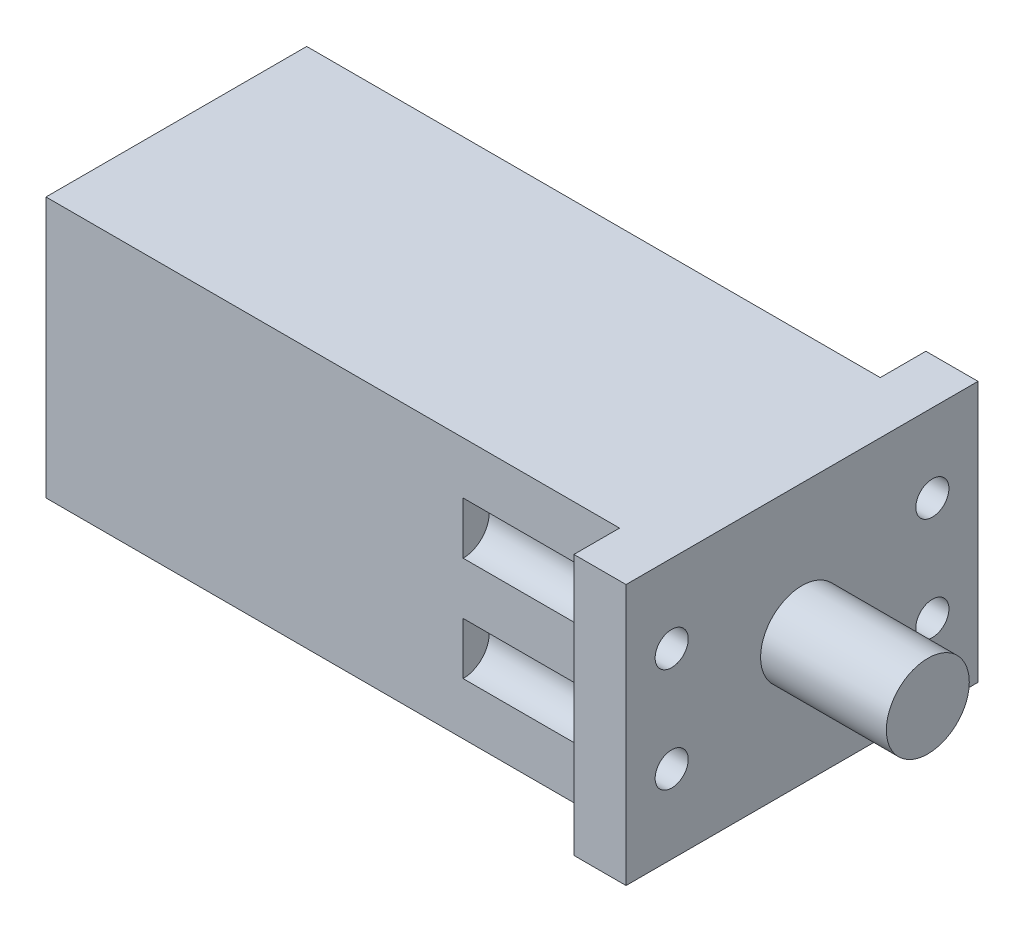
from build123d import *

# Parameters (mm, degrees)
SKETCH1_W           = 100
SKETCH1_H           = 100
BOSS_EXTRUDE1_DEPTH = 240
SKETCH3_W           = 20
SKETCH3_H           = 100
BOSS_EXTRUDE2_DEPTH = 17.5
SKETCH4_W           = 20
SKETCH4_H           = 100
BOSS_EXTRUDE3_DEPTH = 17.5
BOSS_EXTRUDE4_DEPTH = 48.26
CUT_EXTRUDE1_DEPTH  = 20
SKETCH8_R           = 10
CUT_EXTRUDE2_DEPTH  = 60


with BuildPart() as part:
    # Sketch1 → Boss-Extrude1 (new body)
    with BuildSketch(Plane(origin=(0, 0, 0), x_dir=(0, 0, -1), z_dir=(1, 0, 0))):
        with Locations((50, 50)):
            Rectangle(SKETCH1_W, SKETCH1_H)
    extrude(amount=BOSS_EXTRUDE1_DEPTH)

    # Sketch3 → Boss-Extrude2 (add)
    with BuildSketch(Plane.XY):
        with Locations((230, 50)):
            Rectangle(SKETCH3_W, SKETCH3_H)
    extrude(amount=BOSS_EXTRUDE2_DEPTH)

    # Sketch4 → Boss-Extrude3 (add)
    with BuildSketch(Plane(origin=(0, 0, -100), x_dir=(-1, 0, 0), z_dir=(0, 0, -1))):
        with Locations((-230, 50)):
            Rectangle(SKETCH4_W, SKETCH4_H)
    extrude(amount=BOSS_EXTRUDE3_DEPTH)

    # Sketch6 → Boss-Extrude4 (add)
    with BuildSketch(Plane(origin=(240, 0, 0), x_dir=(0, 0, -1), z_dir=(1, 0, 0))):
        with BuildLine():
            ThreePointArc((65.9, 50), (61.242997821, 61.242997821), (50, 65.9))
            Line((50, 65.9), (50, 50))
            Line((50, 50), (34.1, 50))
            ThreePointArc((34.1, 50), (50, 34.1), (65.9, 50))
        make_face()
        with BuildLine():
            Line((50, 50), (50, 65.9))
            ThreePointArc((50, 65.9), (38.757002179, 61.242997821), (34.1, 50))
            Line((34.1, 50), (50, 50))
        make_face()
    extrude(amount=BOSS_EXTRUDE4_DEPTH)

    # Sketch7 → Cut-Extrude1 (cut)
    with BuildSketch(Plane(origin=(240, 0, 0), x_dir=(0, 0, -1), z_dir=(1, 0, 0))):
        with BuildLine():
            Line((0, 63.65), (0, 70))
            Line((0, 70), (6.35, 70))
            ThreePointArc((6.35, 70), (-4.490128061, 74.490128061), (0, 63.65))
        make_face()
        with BuildLine():
            Line((6.35, 70), (0, 70))
            Line((0, 70), (0, 63.65))
            ThreePointArc((0, 63.65), (4.490128061, 65.509871939), (6.35, 70))
        make_face()
        with BuildLine():
            ThreePointArc((6.35, 30), (4.490128061, 34.490128061), (0, 36.35))
            Line((0, 36.35), (0, 30))
            Line((0, 30), (6.35, 30))
        make_face()
        with BuildLine():
            Line((0, 30), (0, 36.35))
            ThreePointArc((0, 36.35), (-4.490128061, 25.509871939), (6.35, 30))
            Line((6.35, 30), (0, 30))
        make_face()
        with BuildLine():
            ThreePointArc((106.35, 30), (104.490128061, 34.490128061), (100, 36.35))
            Line((100, 36.35), (100, 30))
            Line((100, 30), (93.65, 30))
            ThreePointArc((93.65, 30), (100, 23.65), (106.35, 30))
        make_face()
        with BuildLine():
            Line((100, 30), (100, 36.35))
            ThreePointArc((100, 36.35), (95.509871939, 34.490128061), (93.65, 30))
            Line((93.65, 30), (100, 30))
        make_face()
        with BuildLine():
            ThreePointArc((106.35, 70), (100, 76.35), (93.65, 70))
            Line((93.65, 70), (100, 70))
            Line((100, 70), (100, 63.65))
            ThreePointArc((100, 63.65), (104.490128061, 65.509871939), (106.35, 70))
        make_face()
        with BuildLine():
            Line((100, 70), (93.65, 70))
            ThreePointArc((93.65, 70), (95.509871939, 65.509871939), (100, 63.65))
            Line((100, 63.65), (100, 70))
        make_face()
    extrude(amount=-CUT_EXTRUDE1_DEPTH, mode=Mode.SUBTRACT)

    # Sketch8 → Cut-Extrude2 (cut)
    with BuildSketch(Plane.ZY.offset(-220)):
        with Locations((0, 70)):
            Circle(SKETCH8_R)
        with Locations((0, 30)):
            Circle(SKETCH8_R)
        with Locations((-100, 70)):
            Circle(SKETCH8_R)
        with Locations((-100, 30)):
            Circle(SKETCH8_R)
    extrude(amount=CUT_EXTRUDE2_DEPTH, mode=Mode.SUBTRACT)


solid = part.part
